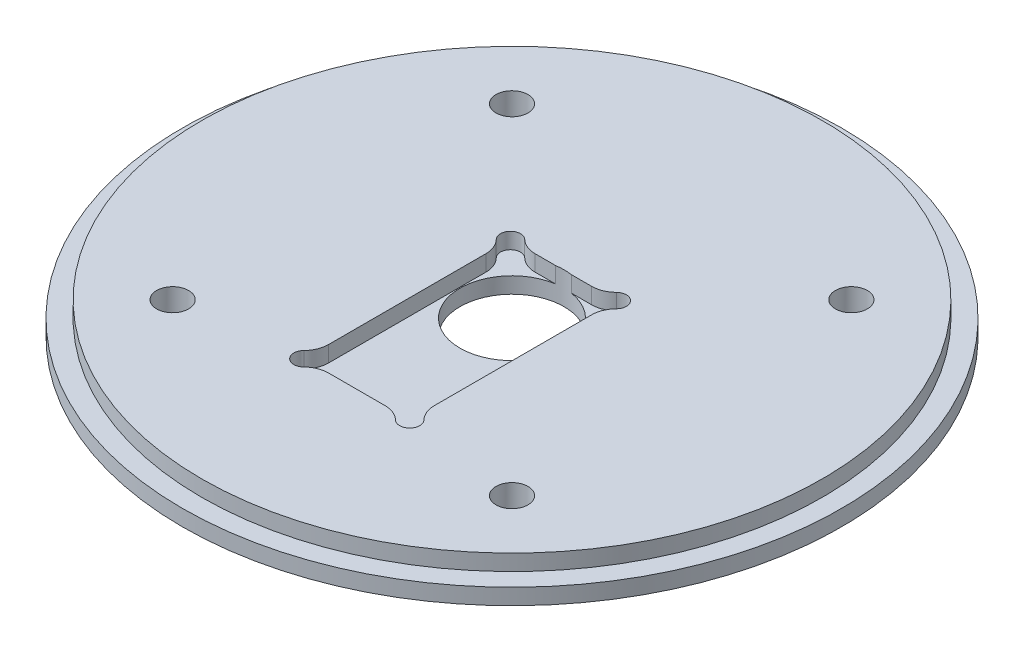
from build123d import *

# Parameters (mm, degrees)
SKETCH2_R                       = 65.405
BOSS_EXTRUDE1_DEPTH             = 6.35
SKETCH4_R                       = 65.405
SKETCH4_R_2                     = 61.595
CUT_EXTRUDE1_DEPTH              = 3.175
F_1_4_0_25_DIAMETER_HOLE1_D     = 6.35
F_13_16_0_8125_DIAMETER_HOLE1_D = 20.6375
CUT_EXTRUDE3_DEPTH              = 3.175
SKETCH9_R                       = 6.0325
CUT_EXTRUDE2_DEPTH              = 1.5875


with BuildPart() as part:
    # Sketch2 → Boss-Extrude1 (new body)
    with BuildSketch(Plane(origin=(0, 0, 0), x_dir=(1, 0, 0), z_dir=(0, 1, 0))):
        Circle(SKETCH2_R)
    extrude(amount=BOSS_EXTRUDE1_DEPTH)

    # Sketch4 → Cut-Extrude1 (cut)
    with BuildSketch(Plane(origin=(0, 6.35, 0), x_dir=(1, 0, 0), z_dir=(0, 1, 0))):
        Circle(SKETCH4_R)
        Circle(SKETCH4_R_2, mode=Mode.SUBTRACT)
    extrude(amount=-CUT_EXTRUDE1_DEPTH, mode=Mode.SUBTRACT)

    # 1/4 (0.25) Diameter Hole1 (through all)
    with Locations(Plane(origin=(0, 6.35, 0), x_dir=(1, 0, 0), z_dir=(0, 1, 0))):
        with Locations((-33.675960454, 33.675960454), (-33.675960454, -33.675960454), (33.675960454, 33.675960454), (33.675960454, -33.675960454)):
            Hole(F_1_4_0_25_DIAMETER_HOLE1_D / 2)

    # 13/16 (0.8125) Diameter Hole1 (through all)
    with Locations(Plane(origin=(0, 6.35, 0), x_dir=(1, 0, 0), z_dir=(0, 1, 0))):
        with Locations((0, 0)):
            Hole(F_13_16_0_8125_DIAMETER_HOLE1_D / 2)

    # Sketch11 → Cut-Extrude3 (cut)
    with BuildSketch(Plane(origin=(0, 6.35, 0), x_dir=(1, 0, 0), z_dir=(0, 1, 0))):
        with BuildLine():
            Line((-5.601020514, 10.2), (5.601020514, 10.2))
            ThreePointArc((5.601020514, 10.2), (7.490842879, 10.570899501), (9.100291576, 11.628571429))
            ThreePointArc((9.100291576, 11.628571429), (11.914213562, 11.614213562), (11.928571429, 8.800291576))
            ThreePointArc((11.928571429, 8.800291576), (10.870899501, 7.190842879), (10.5, 5.301020514))
            Line((10.5, 5.301020514), (10.5, -25.901020514))
            ThreePointArc((10.5, -25.901020514), (10.870899501, -27.790842879), (11.928571429, -29.400291576))
            ThreePointArc((11.928571429, -29.400291576), (11.914213562, -32.214213562), (9.100291576, -32.228571429))
            ThreePointArc((9.100291576, -32.228571429), (7.490842879, -31.170899501), (5.601020514, -30.8))
            Line((5.601020514, -30.8), (-5.601020514, -30.8))
            ThreePointArc((-5.601020514, -30.8), (-7.490842879, -31.170899501), (-9.100291576, -32.228571429))
            ThreePointArc((-9.100291576, -32.228571429), (-11.914213562, -32.214213562), (-11.928571429, -29.400291576))
            ThreePointArc((-11.928571429, -29.400291576), (-10.870899501, -27.790842879), (-10.5, -25.901020514))
            Line((-10.5, -25.901020514), (-10.5, 5.301020514))
            ThreePointArc((-10.5, 5.301020514), (-10.870899501, 7.190842879), (-11.928571429, 8.800291576))
            ThreePointArc((-11.928571429, 8.800291576), (-11.914213562, 11.614213562), (-9.100291576, 11.628571429))
            ThreePointArc((-9.100291576, 11.628571429), (-7.490842879, 10.570899501), (-5.601020514, 10.2))
        make_face()
    extrude(amount=-CUT_EXTRUDE3_DEPTH, mode=Mode.SUBTRACT)

    # Sketch9 → Cut-Extrude2 (cut)
    with BuildSketch(Plane.XZ):
        with Locations((-33.675960454, 33.675960454)):
            Circle(SKETCH9_R)
        with Locations((33.675960454, 33.675960454)):
            Circle(SKETCH9_R)
        with Locations((33.675960454, -33.675960454)):
            Circle(SKETCH9_R)
        with Locations((-33.675960454, -33.675960454)):
            Circle(SKETCH9_R)
    extrude(amount=-CUT_EXTRUDE2_DEPTH, mode=Mode.SUBTRACT)


solid = part.part
